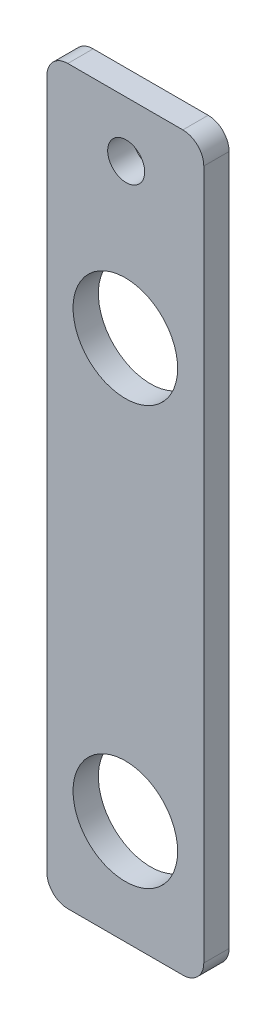
from build123d import *

# Parameters (mm, degrees)
SKETCH1_W             = 19.05
SKETCH1_H             = 88.9
SKETCH1_R             = 6.35
BOSS_EXTRUDE1_DEPTH   = 3.0734
F_8_CLEARANCE_HOLE1_D = 4.4958
FILLET1_R             = 2.54


with BuildPart() as part:
    # Sketch1 → Boss-Extrude1 (new body)
    with BuildSketch(Plane.XY):
        with Locations((9.525, 44.45)):
            Rectangle(SKETCH1_W, SKETCH1_H)
        with Locations((9.525, 12.7)):
            Circle(SKETCH1_R, mode=Mode.SUBTRACT)
        with Locations((9.525, 63.5)):
            Circle(SKETCH1_R, mode=Mode.SUBTRACT)
    extrude(amount=BOSS_EXTRUDE1_DEPTH)

    # #8 Clearance Hole1 (through all)
    with Locations(Plane.XY.offset(3.0734)):
        with Locations((9.627458059, 82.1563)):
            Hole(F_8_CLEARANCE_HOLE1_D / 2)

    # Fillet1
    fillet1_edges = [part.edges().sort_by_distance(p)[0] for p in [
        (0, 88.9, 1.5367),
        (19.05, 88.9, 1.5367),
        (19.05, 0, 1.5367),
        (0, 0, 1.5367),
    ]]
    fillet(fillet1_edges, radius=FILLET1_R)


solid = part.part
